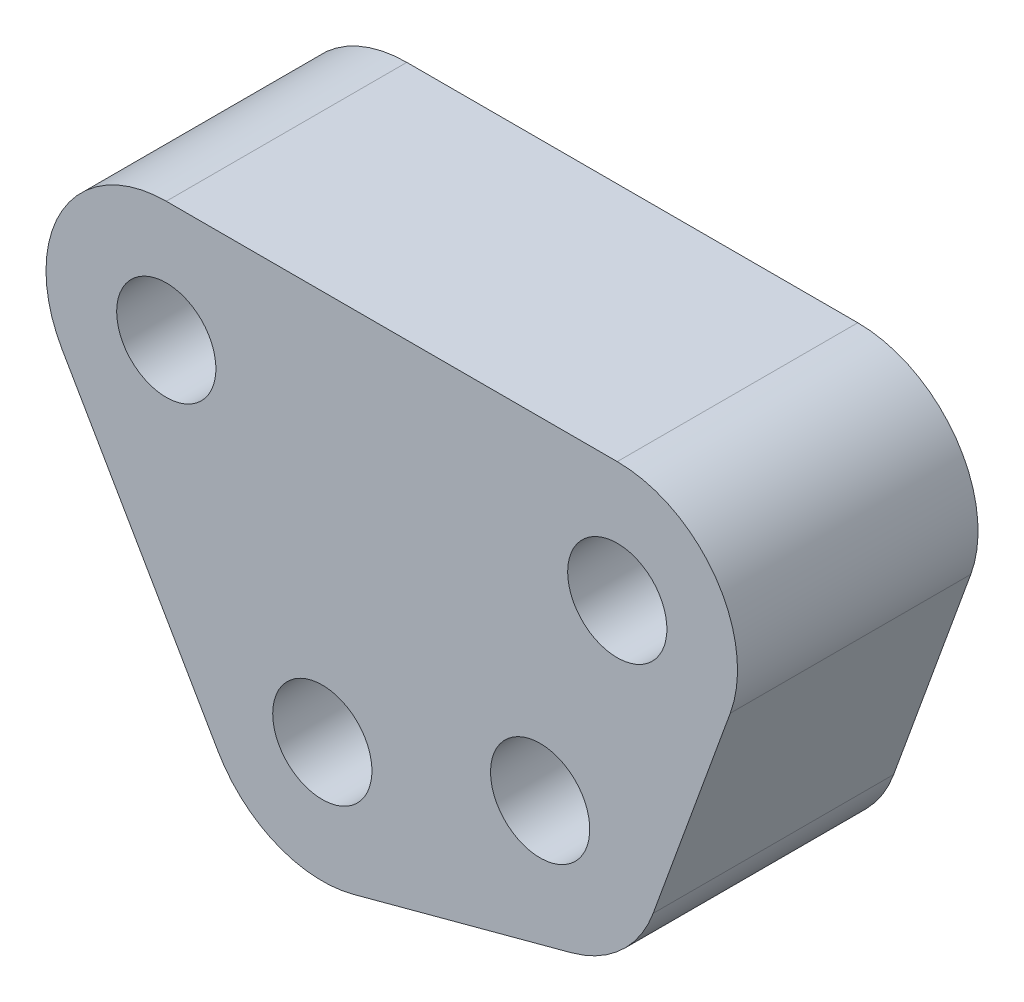
from build123d import *

# Parameters (mm, degrees)
BOSS_EXTRU_1_DEPTH = 8
TROU_TARAUD_M41_D  = 3.3


with BuildPart() as part:
    # Esquisse1 → Boss.-Extru.1 (new body)
    with BuildSketch(Plane.XY):
        with BuildLine():
            Line((-15, 4), (0, 4))
            ThreePointArc((0, 4), (3.276608177, 2.294305745), (3.758770483, -1.368080573))
            Line((3.758770483, -1.368080573), (1.193619408, -8.415775229))
            ThreePointArc((1.193619408, -8.415775229), (0.137209756, -9.996804003), (-1.529874895, -10.911397961))
            Line((-1.529874895, -10.911397961), (-8.774922628, -12.85270265))
            ThreePointArc((-8.774922628, -12.85270265), (-11.340932538, -12.684517475), (-13.274300423, -10.988999345))
            Line((-13.274300423, -10.988999345), (-18.464101615, -2))
            ThreePointArc((-18.464101615, -2), (-18.464101615, 2), (-15, 4))
        make_face()
    extrude(amount=BOSS_EXTRU_1_DEPTH)

    # Trou taraudé M41 (through all)
    with Locations(Plane(origin=(0, 0, 0), x_dir=(1, 0, 0), z_dir=(0, 0, -1))):
        with Locations((-15, 0), (0, 0), (-2.565151075, 7.047694656), (-9.810198808, 8.988999345)):
            Hole(TROU_TARAUD_M41_D / 2)


solid = part.part
